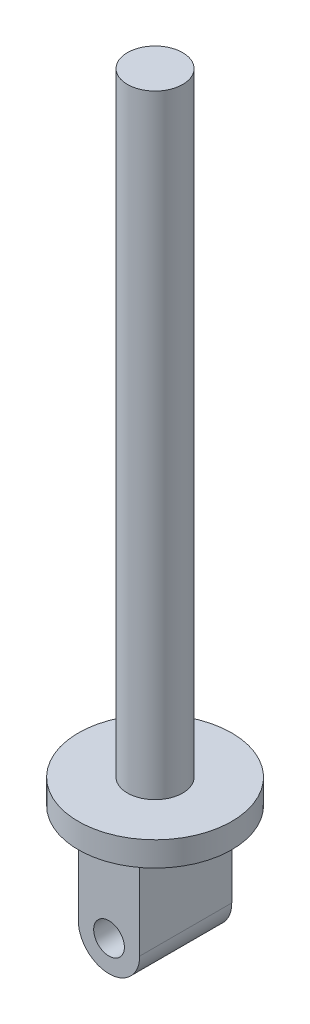
from build123d import *

# Parameters (mm, degrees)
ESBO_O3_R                = 5
RESSALTO_EXTRUS_O1_DEPTH = 15


with BuildPart() as part:
    # Esboço1 → Revolução1 (revolve)
    with BuildSketch(Plane.XY):
        Polygon((0, 200), (9, 200), (9, 0), (25, 0), (25, -8), (0, -8), (0, 0), align=None)
    revolve(axis=Axis((0, 0, 0), (0, 1, 0)))

    # Esboço3 → Ressalto-extrusão1 (add, symmetric)
    with BuildSketch(Plane.XY):
        with BuildLine():
            Line((-10, -8), (10, -8))
            Line((10, -8), (10, -38))
            ThreePointArc((10, -38), (0, -48), (-10, -38))
            Line((-10, -38), (-10, -8))
        make_face()
        with Locations((0, -38)):
            Circle(ESBO_O3_R, mode=Mode.SUBTRACT)
    extrude(amount=RESSALTO_EXTRUS_O1_DEPTH, both=True)


solid = part.part
